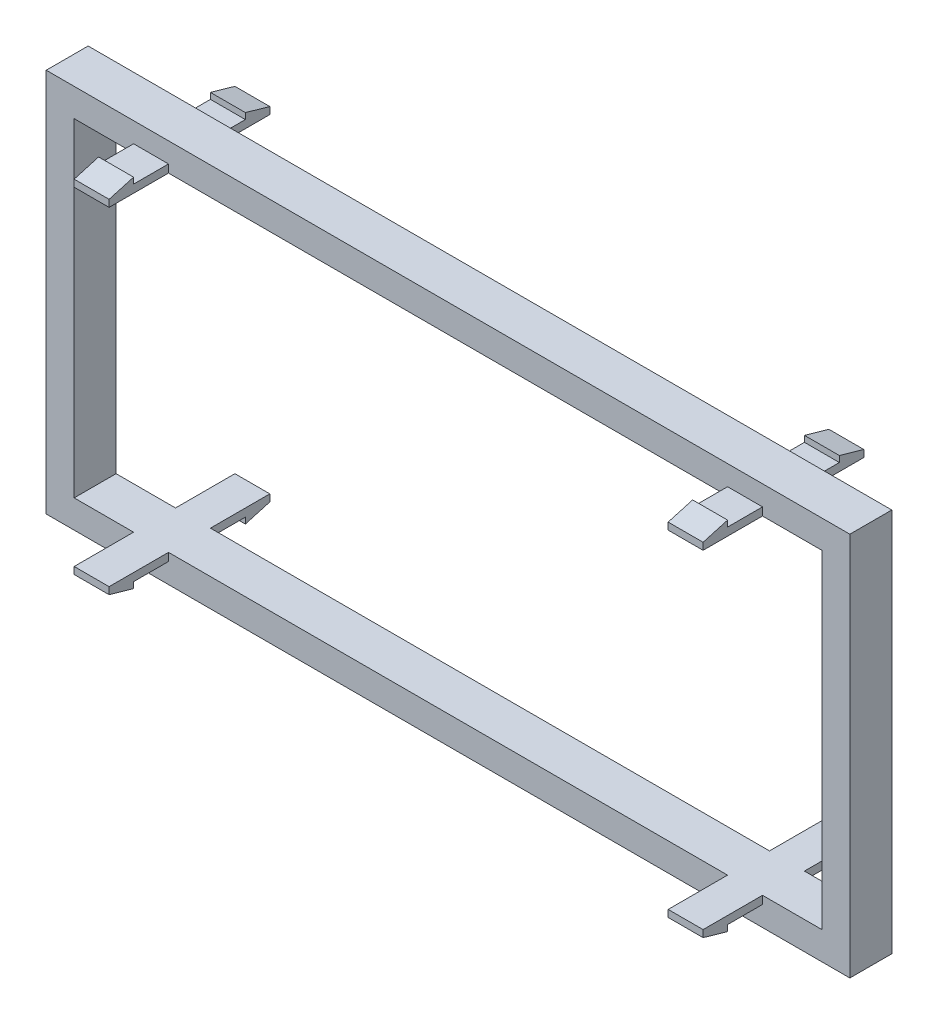
from build123d import *

# Parameters (mm, degrees)
SKETCH1_W               = 115
SKETCH1_H               = 55
SKETCH1_W_2             = 107
SKETCH1_H_2             = 47
BOSS_EXTRUDE1_DEPTH     = 6
SKETCH2_W               = 5
SKETCH2_H               = 2
BOSS_EXTRUDE2_DEPTH     = 8.5
CUT_EXTRUDE1_DEPTH      = 10
MIRROR2_COPY_1_SKETCH_W = 5
MIRROR2_COPY_1_SKETCH_H = 2
MIRROR2_COPY_1_DEPTH    = 8.5
MIRROR2_COPY_2_DEPTH    = 10
MIRROR3_COPY_1_SKETCH_W = 5
MIRROR3_COPY_1_SKETCH_H = 2
MIRROR3_COPY_1_DEPTH    = 8.5
MIRROR3_COPY_2_DEPTH    = 10
MIRROR3_COPY_3_SKETCH_W = 5
MIRROR3_COPY_3_SKETCH_H = 2
MIRROR3_COPY_3_DEPTH    = 8.5
MIRROR3_COPY_4_DEPTH    = 10
MIRROR3_COPY_5_SKETCH_W = 5
MIRROR3_COPY_5_SKETCH_H = 2
MIRROR3_COPY_5_DEPTH    = 8.5
MIRROR3_COPY_6_DEPTH    = 10


with BuildPart() as part:
    # Sketch1 → Boss-Extrude1 (new body)
    with BuildSketch(Plane.XY):
        Rectangle(SKETCH1_W, SKETCH1_H)
        Rectangle(SKETCH1_W_2, SKETCH1_H_2, mode=Mode.SUBTRACT)
    extrude(amount=BOSS_EXTRUDE1_DEPTH)

    # Sketch2 → Boss-Extrude2 (add)
    with BuildSketch(Plane.XY.offset(6)):
        with Locations((-42.5, 24.5)):
            Rectangle(SKETCH2_W, SKETCH2_H)
    boss_extrude2 = extrude(amount=BOSS_EXTRUDE2_DEPTH)

    # Sketch3 → Cut-Extrude1 (cut)
    with BuildSketch(Plane(origin=(-40, 0, 0), x_dir=(0, 0, -1), z_dir=(1, 0, 0))):
        Polygon((-14.5, 24.5), (-11, 25.5), (-11, 24.633842956), (-6, 24.633842956), (-6, 26.874562864), (-14.5, 26.874562864), align=None)
    cut_extrude1 = extrude(amount=-CUT_EXTRUDE1_DEPTH, mode=Mode.SUBTRACT)

    # Mirror1: Boss-Extrude2, Cut-Extrude1 across plane
    add(boss_extrude2.mirror(Plane.ZX))
    add(cut_extrude1.mirror(Plane.ZX), mode=Mode.SUBTRACT)

    # Mirror2: Boss-Extrude2, Cut-Extrude1 across plane
    add(boss_extrude2.mirror(Plane(origin=(0, 0, 0), x_dir=(0, 0, 1), z_dir=(1, 0, 0))))
    add(cut_extrude1.mirror(Plane(origin=(0, 0, 0), x_dir=(0, 0, 1), z_dir=(1, 0, 0))), mode=Mode.SUBTRACT)

    # Mirror2 copy 1 sketch → Mirror2 copy 1 (add)
    with BuildSketch(Plane(origin=(0, 0, 6), x_dir=(-1, 0, 0), z_dir=(0, 0, 1))):
        with Locations((-42.5, 24.5)):
            Rectangle(MIRROR2_COPY_1_SKETCH_W, MIRROR2_COPY_1_SKETCH_H)
    extrude(amount=MIRROR2_COPY_1_DEPTH)

    # Mirror2 copy 2 sketch → Mirror2 copy 2 (cut)
    with BuildSketch(Plane(origin=(40, 0, 0), x_dir=(0, 0, -1), z_dir=(-1, 0, 0))):
        Polygon((-14.5, 24.5), (-11, 25.5), (-11, 24.633842956), (-6, 24.633842956), (-6, 26.874562864), (-14.5, 26.874562864), align=None)
    extrude(amount=-MIRROR2_COPY_2_DEPTH, mode=Mode.SUBTRACT)

    # Mirror3: Boss-Extrude2, Cut-Extrude1 across plane
    add(boss_extrude2.mirror(Plane.XY.offset(3)))
    add(cut_extrude1.mirror(Plane.XY.offset(3)), mode=Mode.SUBTRACT)

    # Mirror3 copy 1 sketch → Mirror3 copy 1 (add)
    with BuildSketch(Plane(origin=(0, 0, 0), x_dir=(-1, 0, 0), z_dir=(0, 0, -1))):
        with Locations((-42.5, 24.5)):
            Rectangle(MIRROR3_COPY_1_SKETCH_W, MIRROR3_COPY_1_SKETCH_H)
    extrude(amount=MIRROR3_COPY_1_DEPTH)

    # Mirror3 copy 2 sketch → Mirror3 copy 2 (cut)
    with BuildSketch(Plane(origin=(40, 0, 6), x_dir=(0, 0, 1), z_dir=(-1, 0, 0))):
        Polygon((-14.5, 24.5), (-11, 25.5), (-11, 24.633842956), (-6, 24.633842956), (-6, 26.874562864), (-14.5, 26.874562864), align=None)
    extrude(amount=-MIRROR3_COPY_2_DEPTH, mode=Mode.SUBTRACT)

    # Mirror3 copy 3 sketch → Mirror3 copy 3 (add)
    with BuildSketch(Plane(origin=(0, 0, 0), x_dir=(-1, 0, 0), z_dir=(0, 0, -1))):
        with Locations((-42.5, -24.5)):
            Rectangle(MIRROR3_COPY_3_SKETCH_W, MIRROR3_COPY_3_SKETCH_H)
    extrude(amount=MIRROR3_COPY_3_DEPTH)

    # Mirror3 copy 4 sketch → Mirror3 copy 4 (cut)
    with BuildSketch(Plane(origin=(40, 0, 6), x_dir=(0, 0, 1), z_dir=(-1, 0, 0))):
        Polygon((-14.5, -24.5), (-11, -25.5), (-11, -24.633842956), (-6, -24.633842956), (-6, -26.874562864), (-14.5, -26.874562864), align=None)
    extrude(amount=-MIRROR3_COPY_4_DEPTH, mode=Mode.SUBTRACT)

    # Mirror3 copy 5 sketch → Mirror3 copy 5 (add)
    with BuildSketch(Plane(origin=(0, 0, 0), x_dir=(1, 0, 0), z_dir=(0, 0, -1))):
        with Locations((-42.5, 24.5)):
            Rectangle(MIRROR3_COPY_5_SKETCH_W, MIRROR3_COPY_5_SKETCH_H)
    extrude(amount=MIRROR3_COPY_5_DEPTH)

    # Mirror3 copy 6 sketch → Mirror3 copy 6 (cut)
    with BuildSketch(Plane(origin=(-40, 0, 6), x_dir=(0, 0, 1), z_dir=(1, 0, 0))):
        Polygon((-14.5, 24.5), (-11, 25.5), (-11, 24.633842956), (-6, 24.633842956), (-6, 26.874562864), (-14.5, 26.874562864), align=None)
    extrude(amount=-MIRROR3_COPY_6_DEPTH, mode=Mode.SUBTRACT)


solid = part.part
